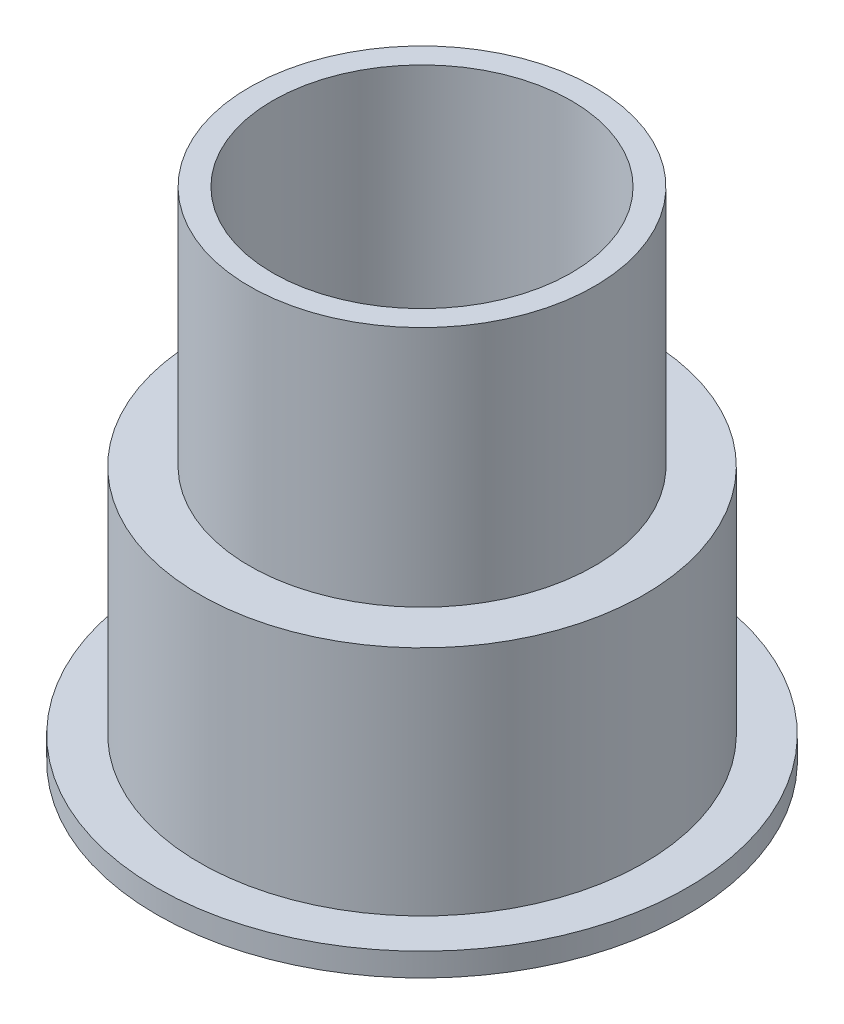
from build123d import *


with BuildPart() as part:
    # Sketch1 → Revolve1 (revolve)
    with BuildSketch(Plane.XY):
        Polygon((6, -0.854835863), (6, 6.145164137), (0, 6.145164137), (0, 6.845164137), (4.5, 6.845164137), (4.5, 14.145164137), (5.2, 14.145164137), (5.2, 6.845164137), (6.7, 6.845164137), (6.7, -0.154835863), (8, -0.154835863), (8, -0.854835863), align=None)
    revolve(axis=Axis((0, 0, 0), (0, 1, 0)))


solid = part.part
